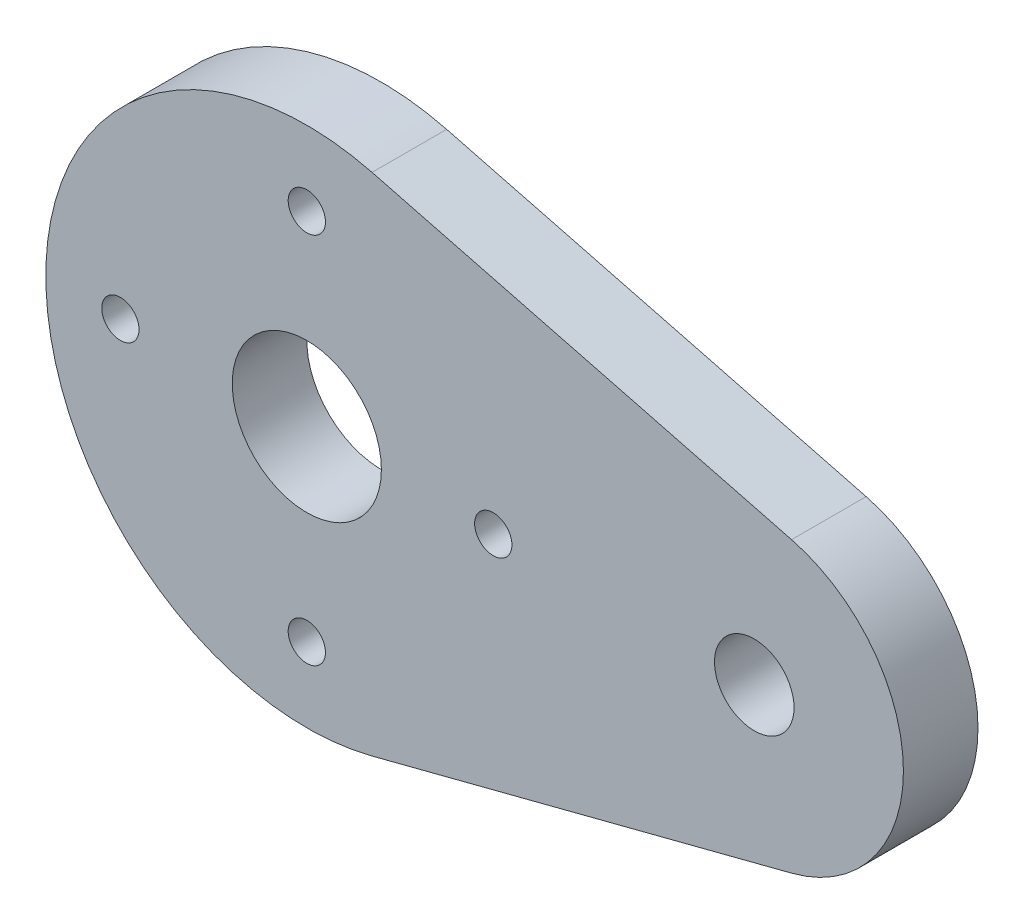
from build123d import *

# Parameters (mm, degrees)
SKETCH_1_R          = 1.6
SKETCH_1_R_2        = 3
EXTRUDE_1_DEPTH     = 3
CUT_EXTRUDE_1_REACH = 5
SKETCH_2_R          = 0.75


with BuildPart() as part:
    # 草图1 → 凸台-拉伸1 (new body)
    with BuildSketch(Plane.XY):
        with BuildLine():
            Line((2.625, 10.166581284), (19.5, 5.809475019))
            ThreePointArc((19.5, 5.809475019), (24, 0), (19.5, -5.809475019))
            Line((19.5, -5.809475019), (2.625, -10.166581284))
            ThreePointArc((2.625, -10.166581284), (-10.5, 0), (2.625, 10.166581284))
        make_face()
        with Locations((18, 0)):
            Circle(SKETCH_1_R, mode=Mode.SUBTRACT)
        Circle(SKETCH_1_R_2, mode=Mode.SUBTRACT)
    extrude(amount=EXTRUDE_1_DEPTH)

    # 草图2 → 切除-拉伸1 (cut, up to next)
    with BuildSketch(Plane.XY.offset(3), mode=Mode.PRIVATE) as cut_extrude_1_sk1:
        with Locations((0, 7.5)):
            Circle(SKETCH_2_R)
    cut_extrude_1_tool1 = extrude(cut_extrude_1_sk1.sketch, amount=-CUT_EXTRUDE_1_REACH, mode=Mode.PRIVATE) & part.part
    add(cut_extrude_1_tool1.solids().sort_by_distance((0, 7.5, 3))[0], mode=Mode.SUBTRACT)
    # 草图2 → 切除-拉伸1 (cut, up to next)
    with BuildSketch(Plane.XY.offset(3), mode=Mode.PRIVATE) as cut_extrude_1_sk2:
        with Locations((7.5, 0)):
            Circle(SKETCH_2_R)
    cut_extrude_1_tool2 = extrude(cut_extrude_1_sk2.sketch, amount=-CUT_EXTRUDE_1_REACH, mode=Mode.PRIVATE) & part.part
    add(cut_extrude_1_tool2.solids().sort_by_distance((7.5, 0, 3))[0], mode=Mode.SUBTRACT)
    # 草图2 → 切除-拉伸1 (cut, up to next)
    with BuildSketch(Plane.XY.offset(3), mode=Mode.PRIVATE) as cut_extrude_1_sk3:
        with Locations((0, -7.5)):
            Circle(SKETCH_2_R)
    cut_extrude_1_tool3 = extrude(cut_extrude_1_sk3.sketch, amount=-CUT_EXTRUDE_1_REACH, mode=Mode.PRIVATE) & part.part
    add(cut_extrude_1_tool3.solids().sort_by_distance((0, -7.5, 3))[0], mode=Mode.SUBTRACT)
    # 草图2 → 切除-拉伸1 (cut, up to next)
    with BuildSketch(Plane.XY.offset(3), mode=Mode.PRIVATE) as cut_extrude_1_sk4:
        with Locations((-7.5, 0)):
            Circle(SKETCH_2_R)
    cut_extrude_1_tool4 = extrude(cut_extrude_1_sk4.sketch, amount=-CUT_EXTRUDE_1_REACH, mode=Mode.PRIVATE) & part.part
    add(cut_extrude_1_tool4.solids().sort_by_distance((-7.5, 0, 3))[0], mode=Mode.SUBTRACT)


solid = part.part
